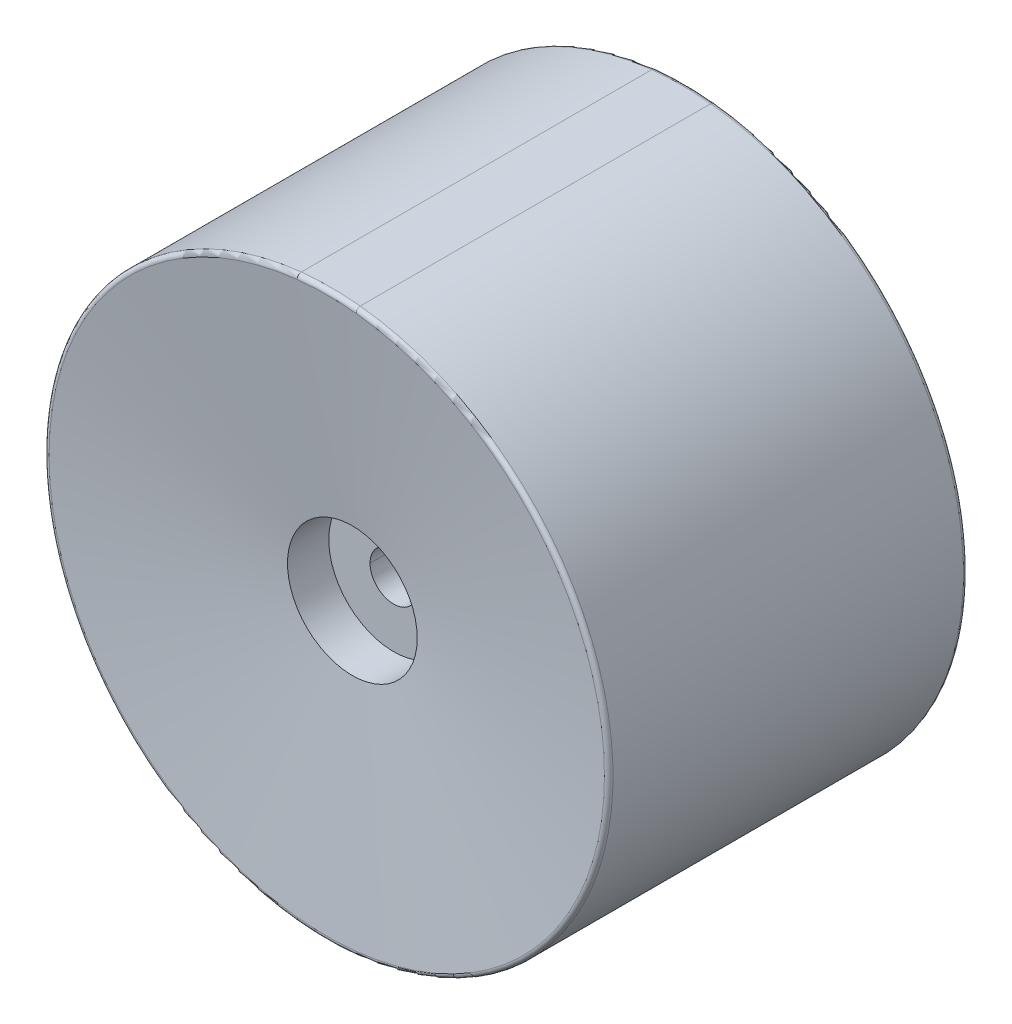
from build123d import *

# Parameters (mm, degrees)
SKETCH1_W          = 11
SKETCH1_H          = 52.107075314
SKETCH3_R          = 11
CUT_EXTRUDE1_DEPTH = 7
SKETCH4_R          = 4
CUT_EXTRUDE2_DEPTH = 50.540387657
SKETCH5_R          = 11
CUT_EXTRUDE3_DEPTH = 7
FILLET2_R          = 0.688


with BuildPart() as part:
    # Sketch1 → Revolve1 (revolve)
    with BuildSketch(Plane(origin=(0, 0, 0), x_dir=(1, 0, 0), z_dir=(0, 1, 0))):
        with Locations((5.5, 0)):
            Rectangle(SKETCH1_W, SKETCH1_H)
        Polygon((11, 26.053537657), (11, -26.053537657), (47.862, -30.48685), (47.862, 30.48685), align=None)
    revolve(axis=Axis((0, 0, 26.053537657), (0, 0, -1)))

    # Sketch3 → Cut-Extrude1 (cut)
    with BuildSketch(Plane.XY.offset(26.053537657)):
        Circle(SKETCH3_R)
    extrude(amount=-CUT_EXTRUDE1_DEPTH, mode=Mode.SUBTRACT)

    # Sketch4 → Cut-Extrude2 (cut, through all)
    with BuildSketch(Plane.XY.offset(19.053537657)):
        Circle(SKETCH4_R)
    extrude(amount=-CUT_EXTRUDE2_DEPTH, mode=Mode.SUBTRACT)

    # Sketch5 → Cut-Extrude3 (cut)
    with BuildSketch(Plane(origin=(0, 0, -26.053537657), x_dir=(-1, 0, 0), z_dir=(0, 0, -1))):
        Circle(SKETCH5_R)
    extrude(amount=-CUT_EXTRUDE3_DEPTH, mode=Mode.SUBTRACT)

    # Fillet2
    fillet2_edges = [part.edges().sort_by_distance(p)[0] for p in [
        (-47.862, 0, -30.48685),
        (-47.862, 0, 30.48685),
    ]]
    fillet(fillet2_edges, radius=FILLET2_R)


solid = part.part
